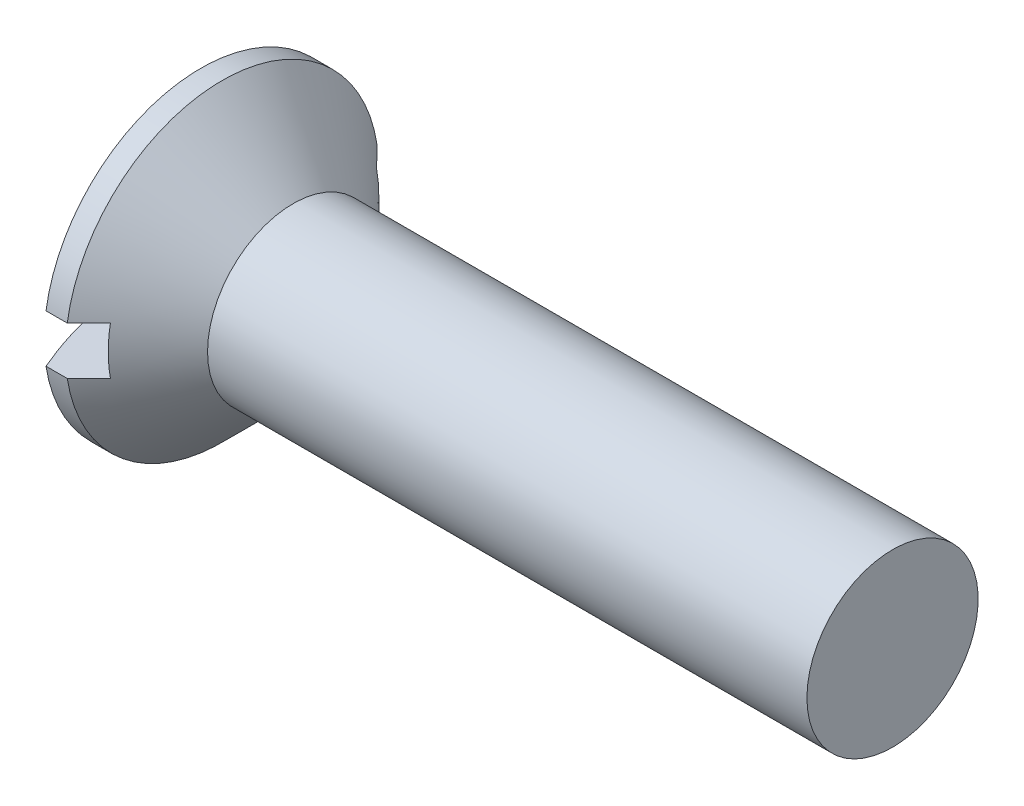
from build123d import *

# Parameters (mm, degrees)
SKETCH2_W         = 18.3
SKETCH2_H         = 2.8
SLOT_DEPTH        = 4.4
SKETCH3_W         = 2.17
SKETCH3_H         = 11.24
SKETCH4_W         = 1.085
SKETCH4_H         = 1.085
CIRPATTERN1_COUNT = 2
CIRPATTERN1_ANGLE = 90


with BuildPart() as part:
    # BodySke → Base-Revolve (revolve)
    with BuildSketch(Plane.XY):
        with BuildLine():
            Line((0, 0), (42.298786444, 0))
            Line((42.298786444, 0), (42.298786444, 5))
            Line((42.298786444, 5), (7.298786444, 5))
            Line((7.298786444, 5), (3.148786444, 9.15))
            Line((3.148786444, 9.15), (1.907441795, 9.15))
            ThreePointArc((1.907441795, 9.15), (0.481931585, 4.673350891), (0, 0))
        make_face()
    revolve(axis=Axis((-15.875, 0, 0), (1, 0, 0)))

    # Sketch2 → Slot (cut)
    with BuildSketch(Plane(origin=(0, 0, 0), x_dir=(0, 0, -1), z_dir=(1, 0, 0))):
        Rectangle(SKETCH2_W, SKETCH2_H)
    extrude(amount=SLOT_DEPTH, mode=Mode.SUBTRACT)

    # Sketch3 → Cross section 0
    with BuildSketch(Plane(origin=(0, 0, 0), x_dir=(0, 0, -1), z_dir=(1, 0, 0))):
        Rectangle(SKETCH3_W, SKETCH3_H)
    # Sketch4 → Cross section 1
    with BuildSketch(Plane(origin=(7.15, 0, 0), x_dir=(0, 0, -1), z_dir=(1, 0, 0))):
        Rectangle(SKETCH4_W, SKETCH4_H)
    cross = loft(mode=Mode.SUBTRACT)

    # CirPattern1: Cross ×2 about axis
    cirpattern1_axis = Axis((0, 0, 0), (1, 0, 0))
    for i in range(1, CIRPATTERN1_COUNT):
        add(cross.rotate(cirpattern1_axis, i * CIRPATTERN1_ANGLE / (CIRPATTERN1_COUNT - 1)), mode=Mode.SUBTRACT)


solid = part.part
